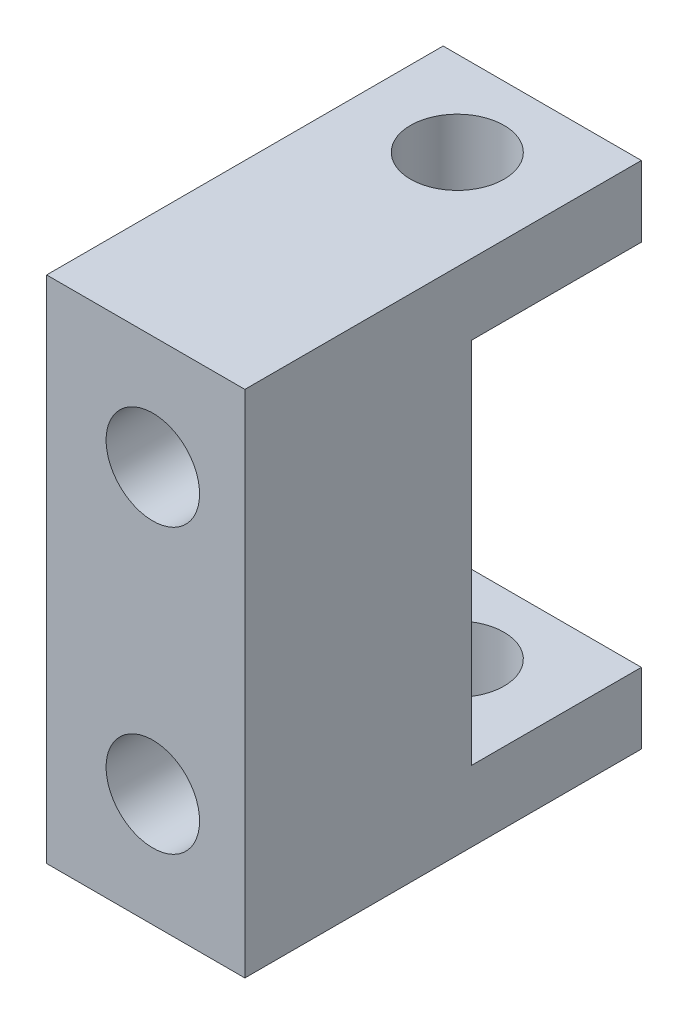
from build123d import *

# Parameters (mm, degrees)
SKETCH1_W                           = 7
SKETCH1_H                           = 18
EXTRUDE1_DEPTH                      = 8
M4X0_7_TAPPED_HOLE1_D               = 3.3
SKETCH7_W                           = 7
SKETCH7_H                           = 2.5
EXTRUDE5_DEPTH                      = 6
M4X0_7_TAPPED_HOLE2_D               = 3.3
M4X0_7_TAPPED_HOLE2_DEPTH           = 10.3
M4X0_7_TAPPED_HOLE2_TIP             = 0.991420021
M4X0_7_TAPPED_HOLE2_ON_FACE_2_D     = 3.3
M4X0_7_TAPPED_HOLE2_ON_FACE_2_DEPTH = 10.3
M4X0_7_TAPPED_HOLE2_ON_FACE_2_TIP   = 0.991420021


with BuildPart() as part:
    # Sketch1 → Extrude1 (new body)
    with BuildSketch(Plane.XY):
        with Locations((-3.5, 9)):
            Rectangle(SKETCH1_W, SKETCH1_H)
    extrude(amount=EXTRUDE1_DEPTH)

    # M4x0.7 Tapped Hole1 (through all)
    with Locations(Plane(origin=(-3.25, 4, 8), x_dir=(1, 0, 0), z_dir=(0, 0, 1))):
        with Locations((0, 0), (0, 10)):
            Hole(M4X0_7_TAPPED_HOLE1_D / 2)

    # Sketch7 → Extrude5 (add)
    with BuildSketch(Plane(origin=(0, 0, 0), x_dir=(-1, 0, 0), z_dir=(0, 0, -1))):
        with Locations((3.5, 16.75)):
            Rectangle(SKETCH7_W, SKETCH7_H)
        with Locations((3.5, 1.25)):
            Rectangle(SKETCH7_W, SKETCH7_H)
    extrude(amount=EXTRUDE5_DEPTH)

    # M4x0.7 Tapped Hole2
    with Locations(Plane(origin=(-3.5, 18, -3), x_dir=(0, 0, 1), z_dir=(0, 1, 0))):
        with Locations((0, 0)):
            Hole(M4X0_7_TAPPED_HOLE2_D / 2, depth=M4X0_7_TAPPED_HOLE2_DEPTH)
            with Locations((0, 0, -(M4X0_7_TAPPED_HOLE2_DEPTH + M4X0_7_TAPPED_HOLE2_TIP / 2))):  # 118° drill point
                Cone(0, M4X0_7_TAPPED_HOLE2_D / 2, M4X0_7_TAPPED_HOLE2_TIP, mode=Mode.SUBTRACT)

    # M4x0.7 Tapped Hole2 on face 2
    with Locations(Plane(origin=(-3.5, 0, -3), x_dir=(0, 0, -1), z_dir=(0, -1, 0))):
        with Locations((0, 0)):
            Hole(M4X0_7_TAPPED_HOLE2_ON_FACE_2_D / 2, depth=M4X0_7_TAPPED_HOLE2_ON_FACE_2_DEPTH)
            with Locations((0, 0, -(M4X0_7_TAPPED_HOLE2_ON_FACE_2_DEPTH + M4X0_7_TAPPED_HOLE2_ON_FACE_2_TIP / 2))):  # 118° drill point
                Cone(0, M4X0_7_TAPPED_HOLE2_ON_FACE_2_D / 2, M4X0_7_TAPPED_HOLE2_ON_FACE_2_TIP, mode=Mode.SUBTRACT)


solid = part.part
